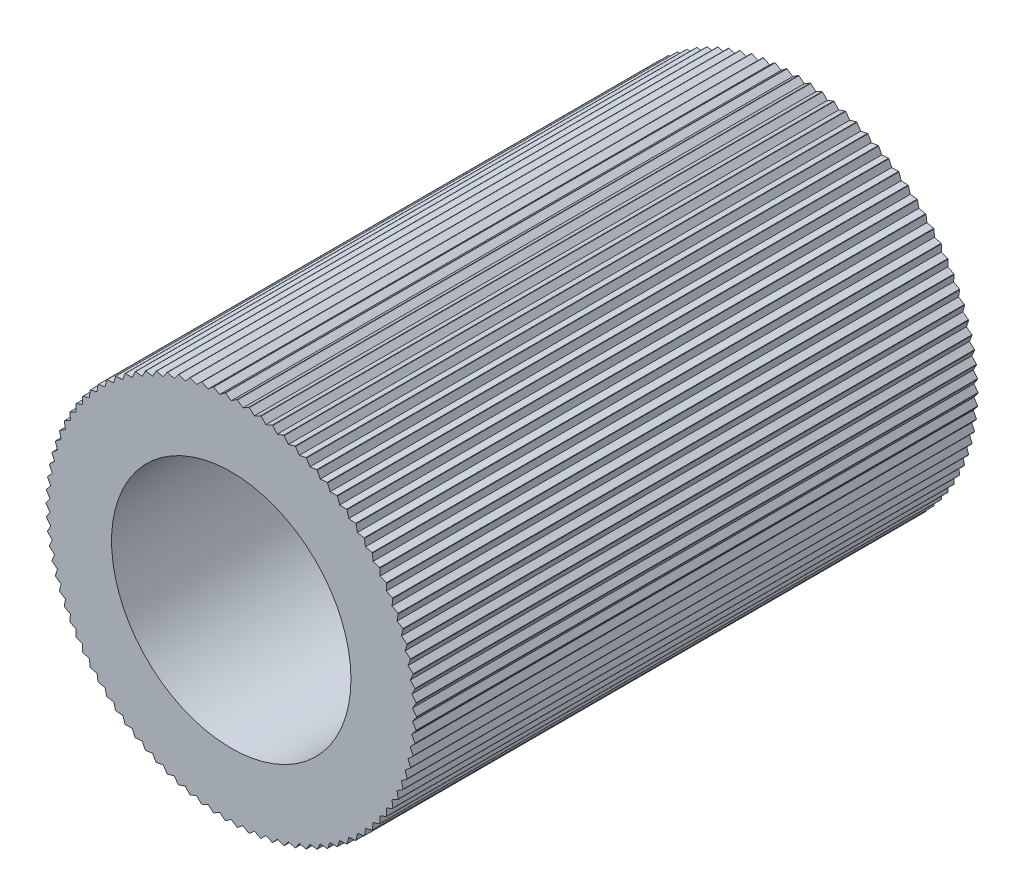
from build123d import *

# Parameters (mm, degrees)
CROQUIS1_R                                 = 3.25
SALIENTE_EXTRUIR1_DEPTH                    = 9.85
PERFORADOR_PARA_ROSCAR_PARA_MACHO_DE_ROS_D = 4.2
CORTAR_EXTRUIR1_DEPTH                      = 10
MATRIZC1_COUNT                             = 98


with BuildPart() as part:
    # Croquis1 → Saliente-Extruir1 (new body)
    with BuildSketch(Plane.XY):
        Circle(CROQUIS1_R)
    extrude(amount=SALIENTE_EXTRUIR1_DEPTH)

    # Perforador para roscar para macho de roscar para M52 (through all)
    with Locations(Plane.XY.offset(9.85)):
        with Locations((0, 0)):
            Hole(PERFORADOR_PARA_ROSCAR_PARA_MACHO_DE_ROS_D / 2)

    # Croquis6 → Cortar-Extruir1 (cut)
    with BuildSketch(Plane.XY.offset(9.85)):
        with BuildLine():
            Line((-0.1, 3.248461174), (0, 3.180759787))
            Line((0, 3.180759787), (0.1, 3.248461174))
            ThreePointArc((0.1, 3.248461174), (0, 3.25), (-0.1, 3.248461174))
        make_face()
    cortar_extruir1 = extrude(amount=-CORTAR_EXTRUIR1_DEPTH, mode=Mode.SUBTRACT)

    # MatrizC1: Cortar-Extruir1 ×98 about axis
    matrizc1_axis = Axis((0, 0, 0), (0, 0, 1))
    for i in range(1, MATRIZC1_COUNT):
        add(cortar_extruir1.rotate(matrizc1_axis, i * 360 / MATRIZC1_COUNT), mode=Mode.SUBTRACT)


solid = part.part
